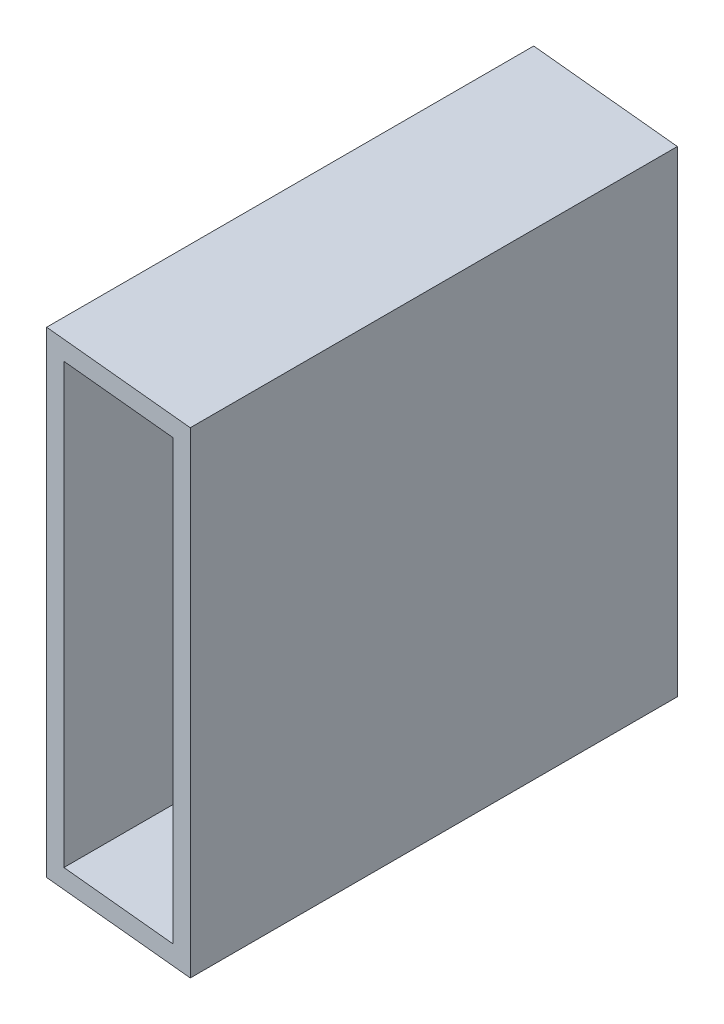
from build123d import *

# Parameters (mm, degrees)
SKETCH2_W               = 9.652
SKETCH2_H               = 3.048
SKETCH2_W_2             = 3.048
SKETCH2_H_2             = 35.052
BOSS_EXTRUDE1_DEPTH     = 77.882279
SKETCH3_W               = 25.4
SKETCH3_H               = 76.2
SKETCH3_W_2             = 19.304
SKETCH3_H_2             = 70.104
BOSS_EXTRUDE2_DEPTH     = 50
CUT_EXTRUDE1_DEPTH      = 1
CUT_EXTRUDE1_DEPTH_BACK = 77.2
SKETCH5_W               = 25.4
SKETCH5_H               = 76.2
SKETCH5_W_2             = 19.304
SKETCH5_H_2             = 70.104
BOSS_EXTRUDE3_DEPTH     = 50
CUT_EXTRUDE2_DEPTH      = 1
CUT_EXTRUDE2_DEPTH_BACK = 77.2


with BuildPart() as part:
    # Sketch2 → Boss-Extrude1 (new body)
    with BuildSketch(Plane.XY):
        Polygon((-12.7, 0), (-9.652, 0), (-9.652, 35.052), (-9.652, 38.1), (-12.7, 38.1), align=None)
        with Locations((-4.826, 36.576)):
            Rectangle(SKETCH2_W, SKETCH2_H)
        Polygon((0, 38.1), (0, 35.052), (9.652, 35.052), (9.652, 0), (12.7, 0), (12.7, 38.1), align=None)
        with Locations((11.176, -17.526)):
            Rectangle(SKETCH2_W_2, SKETCH2_H_2)
        Polygon((-9.652, -35.052), (-9.652, 0), (-12.7, 0), (-12.7, -38.1), (0, -38.1), (0, -35.052), align=None)
        Polygon((9.652, -35.052), (0, -35.052), (0, -38.1), (12.7, -38.1), (12.7, -35.052), align=None)
    extrude(amount=BOSS_EXTRUDE1_DEPTH)

    # Sketch3 → Boss-Extrude2 (add)
    with BuildSketch(Plane(origin=(0, 0, 0), x_dir=(-1, 0, 0), z_dir=(0, 0, -1))):
        Rectangle(SKETCH3_W, SKETCH3_H)
        Rectangle(SKETCH3_W_2, SKETCH3_H_2, mode=Mode.SUBTRACT)
    extrude(amount=BOSS_EXTRUDE2_DEPTH)

    # Sketch4 → Cut-Extrude1 (cut, two sides)
    with BuildSketch(Plane(origin=(0, 38.1, 0), x_dir=(1, 0, 0), z_dir=(0, 1, 0))) as cut_extrude1_sk:
        Polygon((-119.729528752, 11.480724374), (-12.7, 1.217788135), (-12.7, 42.627933021), align=None)
        Polygon((-12.7, 1.217788135), (0, 0), (9.501519639, 49.088910403), (-12.7, 42.627933021), align=None)
        Polygon((12.7, -1.217788135), (119.729528752, -11.480724374), (127.176846342, 66.185439926), (-112.282211162, 89.146888673), (-119.729528752, 11.480724374), (-12.7, 42.627933021), (-12.7, 50), (12.7, 50), align=None)
        Polygon((0, 0), (12.7, -1.217788135), (12.7, 50), (-12.7, 50), (-12.7, 42.627933021), (9.501519639, 49.088910403), align=None)
    extrude(amount=CUT_EXTRUDE1_DEPTH, mode=Mode.SUBTRACT)
    extrude(cut_extrude1_sk.sketch, amount=-CUT_EXTRUDE1_DEPTH_BACK, mode=Mode.SUBTRACT)

    # Sketch5 → Boss-Extrude3 (add)
    with BuildSketch(Plane.XY.offset(77.882278635)):
        Rectangle(SKETCH5_W, SKETCH5_H)
        Rectangle(SKETCH5_W_2, SKETCH5_H_2, mode=Mode.SUBTRACT)
    extrude(amount=BOSS_EXTRUDE3_DEPTH)

    # Sketch6 → Cut-Extrude2 (cut, two sides)
    with BuildSketch(Plane.XZ.offset(38.1)) as cut_extrude2_sk:
        Polygon((-113.161207677, 166.450733215), (-103.71485858, 67.93718224), (-12.7, 124.967023668), (-12.7, 127.882278635), (12.7, 127.882278635), (12.7, 79.100066771), (103.71485858, 87.827375031), (94.268509483, 186.340926006), align=None)
        Polygon((-12.7, 124.967023668), (-103.71485858, 67.93718224), (-12.7, 76.6644905), align=None)
        Polygon((-12.7, 127.882278635), (-12.7, 124.967023668), (-9.501519639, 126.971189038), (0, 77.882278635), (12.7, 79.100066771), (12.7, 127.882278635), align=None)
        Polygon((-12.7, 124.967023668), (-12.7, 76.6644905), (0, 77.882278635), (-9.501519639, 126.971189038), align=None)
    extrude(amount=CUT_EXTRUDE2_DEPTH, mode=Mode.SUBTRACT)
    extrude(cut_extrude2_sk.sketch, amount=-CUT_EXTRUDE2_DEPTH_BACK, mode=Mode.SUBTRACT)


solid = part.part
